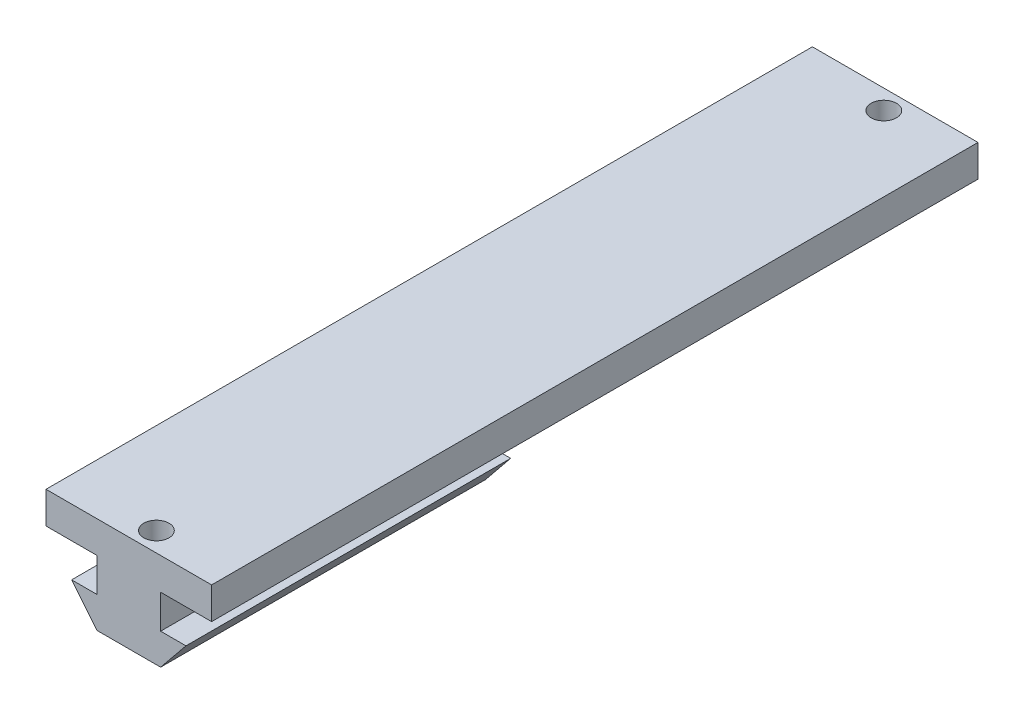
from build123d import *

# Parameters (mm, degrees)
SKETCH1_W           = 25.5
SKETCH1_H           = 118
BOSS_EXTRUDE1_DEPTH = 4.9
BOSS_EXTRUDE5_DEPTH = 50
SKETCH2_R           = 1.95
CUT_EXTRUDE1_DEPTH  = 10


with BuildPart() as part:
    # Sketch1 → Boss-Extrude1 (new body)
    with BuildSketch(Plane(origin=(0, 0, 0), x_dir=(1, 0, 0), z_dir=(0, 1, 0))):
        Rectangle(SKETCH1_W, SKETCH1_H)
    extrude(amount=BOSS_EXTRUDE1_DEPTH)

    # Sketch5 → Boss-Extrude5 (add)
    with BuildSketch(Plane.XY.offset(59)):
        Polygon((-4.9, 0), (-4.9, -5.2), (-8.8, -5.2), (-4.9, -10), (4.9, -10), (8.8, -5.2), (4.9, -5.2), (4.9, 0), align=None)
    extrude(amount=-BOSS_EXTRUDE5_DEPTH)

    # Sketch2 → Cut-Extrude1 (cut)
    with BuildSketch(Plane(origin=(0, 4.9, 0), x_dir=(1, 0, 0), z_dir=(0, 1, 0))):
        with Locations((1.25, 56)):
            Circle(SKETCH2_R)
        with Locations((1.25, -56)):
            Circle(SKETCH2_R)
    extrude(amount=-CUT_EXTRUDE1_DEPTH, mode=Mode.SUBTRACT)


solid = part.part
